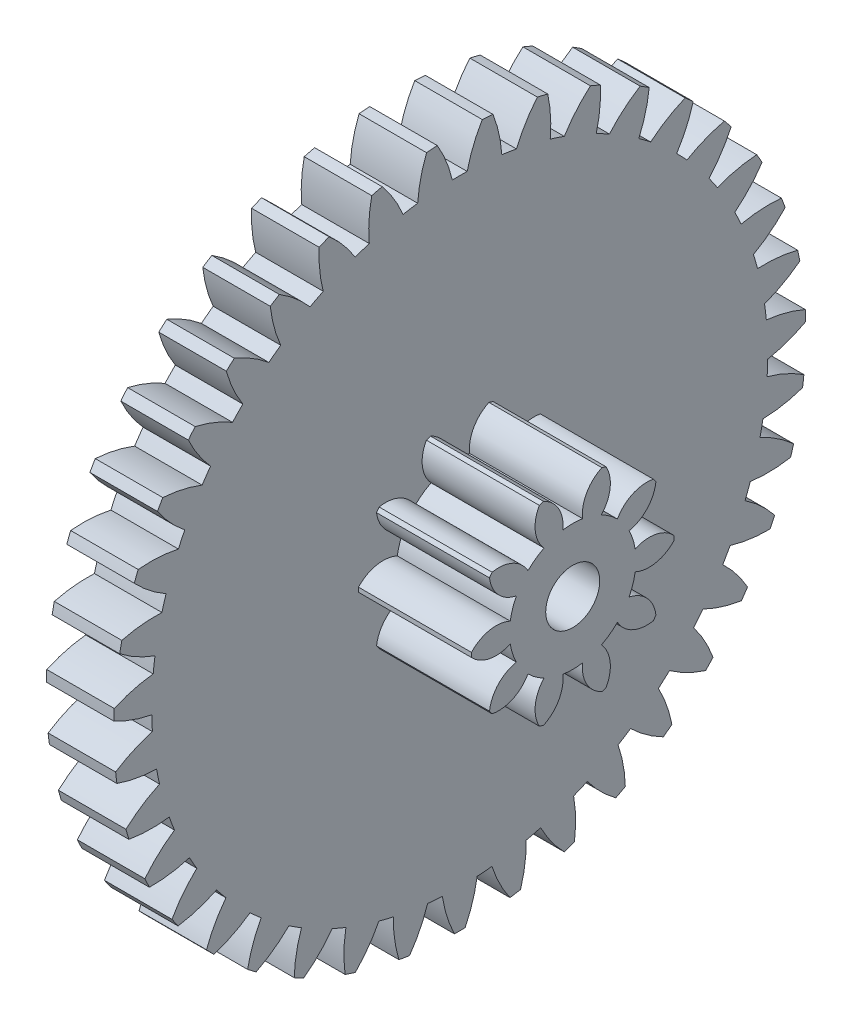
from build123d import *

# Parameters (mm, degrees)
ESQUISSE1_W                         = 1
ESQUISSE1_H                         = 5.125
ENL_V_MAT_EXTRU_1_DEPTH             = 2
ENL_V_MAT_EXTRU_2_DEPTH             = 2
ENL_V_MAT_EXTRU_3_DEPTH             = 2
ENL_V_MAT_EXTRU_4_DEPTH             = 2
ENL_V_MAT_EXTRU_5_DEPTH             = 2
ENL_V_MAT_EXTRU_6_DEPTH             = 2
ENL_V_MAT_EXTRU_7_DEPTH             = 2
ENL_V_MAT_EXTRU_8_DEPTH             = 2
ENL_V_MAT_EXTRU_9_DEPTH             = 2
ENL_V_MAT_EXTRU_10_DEPTH            = 2
ENL_V_MAT_EXTRU_11_DEPTH            = 2
ENL_V_MAT_EXTRU_12_DEPTH            = 2
ENL_V_MAT_EXTRU_13_DEPTH            = 2
ENL_V_MAT_EXTRU_14_DEPTH            = 2
ENL_V_MAT_EXTRU_15_DEPTH            = 2
ENL_V_MAT_EXTRU_16_DEPTH            = 2
ENL_V_MAT_EXTRU_17_DEPTH            = 2
ENL_V_MAT_EXTRU_18_DEPTH            = 2
ENL_V_MAT_EXTRU_19_DEPTH            = 2
ENL_V_MAT_EXTRU_20_DEPTH            = 2
ENL_V_MAT_EXTRU_21_DEPTH            = 2
ENL_V_MAT_EXTRU_22_DEPTH            = 2
ENL_V_MAT_EXTRU_23_DEPTH            = 2
ENL_V_MAT_EXTRU_24_DEPTH            = 2
ENL_V_MAT_EXTRU_25_DEPTH            = 2
ENL_V_MAT_EXTRU_26_DEPTH            = 2
ENL_V_MAT_EXTRU_27_DEPTH            = 2
ENL_V_MAT_EXTRU_28_DEPTH            = 2
ENL_V_MAT_EXTRU_29_DEPTH            = 2
ENL_V_MAT_EXTRU_30_DEPTH            = 2
ENL_V_MAT_EXTRU_31_DEPTH            = 2
ENL_V_MAT_EXTRU_32_DEPTH            = 2
ENL_V_MAT_EXTRU_33_DEPTH            = 2
ENL_V_MAT_EXTRU_34_DEPTH            = 2
ENL_V_MAT_EXTRU_35_DEPTH            = 2
ENL_V_MAT_EXTRU_36_DEPTH            = 2
ENL_V_MAT_EXTRU_37_DEPTH            = 2
ENL_V_MAT_EXTRU_38_DEPTH            = 2
ENL_V_MAT_EXTRU_39_DEPTH            = 2
BOSS_EXTRU_1_DEPTH                  = 1.672761457
DIAM_TRE_DU_PER_AGE_0_8_0_8_1_D     = 0.8
DIAM_TRE_DU_PER_AGE_0_8_0_8_1_DEPTH = 2.672761457


with BuildPart() as part:
    # Esquisse1 → Révolution1 (revolve)
    with BuildSketch(Plane(origin=(0, 0, 0), x_dir=(-1, 0, 0), z_dir=(0, 0, -1))):
        with Locations((-0.5, 2.5625)):
            Rectangle(ESQUISSE1_W, ESQUISSE1_H)
    revolve(axis=Axis((1, 0, 0), (-1, 0, 0)))

    # Esquisse2 → Enlèv. mat.-Extru.1 (cut, through all)
    with BuildSketch(Plane.ZY):
        with BuildLine():
            ThreePointArc((-0.491599352, 5.101367961), (-0.822107814, 5.058632596), (-1.149140058, 4.994507196))
            ThreePointArc((-1.149140058, 4.994507196), (-0.974871828, 4.75090918), (-0.839964848, 4.483496549))
            ThreePointArc((-0.839964848, 4.483496549), (-0.731716058, 4.502429773), (-0.623042589, 4.518749847))
            ThreePointArc((-0.623042589, 4.518749847), (-0.579759423, 4.815121196), (-0.491599352, 5.101367961))
        make_face()
    extrude(amount=-ENL_V_MAT_EXTRU_1_DEPTH, mode=Mode.SUBTRACT)

    # Esquisse3 → Enlèv. mat.-Extru.2 (cut, through all)
    with BuildSketch(Plane.ZY):
        with BuildLine():
            ThreePointArc((0.3330837, 5.114164668), (0, 5.125), (-0.3330837, 5.114164668))
            ThreePointArc((-0.3330837, 5.114164668), (-0.200148067, 4.845766593), (-0.1098841, 4.560176283))
            ThreePointArc((-0.1098841, 4.560176283), (0, 4.5615), (0.1098841, 4.560176283))
            ThreePointArc((0.1098841, 4.560176283), (0.200148067, 4.845766593), (0.3330837, 5.114164668))
        make_face()
    extrude(amount=-ENL_V_MAT_EXTRU_2_DEPTH, mode=Mode.SUBTRACT)

    # Esquisse4 → Enlèv. mat.-Extru.3 (cut, through all)
    with BuildSketch(Plane.ZY):
        with BuildLine():
            ThreePointArc((1.149140058, 4.994507196), (0.822107814, 5.058632596), (0.491599352, 5.101367961))
            ThreePointArc((0.491599352, 5.101367961), (0.579759423, 4.815121196), (0.623042589, 4.518749847))
            ThreePointArc((0.623042589, 4.518749847), (0.731716058, 4.502429773), (0.839964848, 4.483496549))
            ThreePointArc((0.839964848, 4.483496549), (0.974871828, 4.75090918), (1.149140058, 4.994507196))
        make_face()
    extrude(amount=-ENL_V_MAT_EXTRU_3_DEPTH, mode=Mode.SUBTRACT)

    # Esquisse5 → Enlèv. mat.-Extru.4 (cut, through all)
    with BuildSketch(Plane.ZY):
        with BuildLine():
            ThreePointArc((1.935434293, 4.745494611), (1.622923468, 4.861249265), (1.303550238, 4.956448504))
            ThreePointArc((1.303550238, 4.956448504), (1.34465145, 4.65976669), (1.339832802, 4.360290164))
            ThreePointArc((1.339832802, 4.360290164), (1.444481054, 4.32674898), (1.548290948, 4.290696609))
            ThreePointArc((1.548290948, 4.290696609), (1.724346921, 4.533005716), (1.935434293, 4.745494611))
        make_face()
    extrude(amount=-ENL_V_MAT_EXTRU_4_DEPTH, mode=Mode.SUBTRACT)

    # Esquisse6 → Enlèv. mat.-Extru.5 (cut, through all)
    with BuildSketch(Plane.ZY):
        with BuildLine():
            ThreePointArc((2.671601796, 4.373576208), (2.381706257, 4.537962131), (2.081739858, 4.683159635))
            ThreePointArc((2.081739858, 4.683159635), (2.07471771, 4.383726673), (2.021922049, 4.088901256))
            ThreePointArc((2.021922049, 4.088901256), (2.119834749, 4.039007661), (2.216517126, 3.986769881))
            ThreePointArc((2.216517126, 3.986769881), (2.429162334, 4.197699784), (2.671601796, 4.373576208))
        make_face()
    extrude(amount=-ENL_V_MAT_EXTRU_5_DEPTH, mode=Mode.SUBTRACT)

    # Esquisse7 → Enlèv. mat.-Extru.6 (cut, through all)
    with BuildSketch(Plane.ZY):
        with BuildLine():
            ThreePointArc((3.338576216, 3.888384478), (3.078804104, 4.097144162), (2.806013509, 4.28857939))
            ThreePointArc((2.806013509, 4.28857939), (2.751049871, 3.994150439), (2.651644577, 3.711611952))
            ThreePointArc((2.651644577, 3.711611952), (2.740285838, 3.646658165), (2.827336674, 3.579587907))
            ThreePointArc((2.827336674, 3.579587907), (3.071063719, 3.753675633), (3.338576216, 3.888384478))
        make_face()
    extrude(amount=-ENL_V_MAT_EXTRU_6_DEPTH, mode=Mode.SUBTRACT)

    # Esquisse8 → Enlèv. mat.-Extru.7 (cut, through all)
    with BuildSketch(Plane.ZY):
        with BuildLine():
            ThreePointArc((3.919083265, 3.302485634), (3.696162543, 3.550212312), (3.457612884, 3.782927193))
            ThreePointArc((3.457612884, 3.782927193), (3.356131286, 3.501127806), (3.212690904, 3.23819385))
            ThreePointArc((3.212690904, 3.23819385), (3.289764964, 3.159862139), (3.364929688, 3.079696486))
            ThreePointArc((3.364929688, 3.079696486), (3.633426167, 3.212433254), (3.919083265, 3.302485634))
        make_face()
    extrude(amount=-ENL_V_MAT_EXTRU_7_DEPTH, mode=Mode.SUBTRACT)

    # Esquisse9 → Enlèv. mat.-Extru.8 (cut, through all)
    with BuildSketch(Plane.ZY):
        with BuildLine():
            ThreePointArc((4.398088117, 2.631054146), (4.217792313, 2.911331827), (4.019661902, 3.179299168))
            ThreePointArc((4.019661902, 3.179299168), (3.874290663, 2.917427803), (3.690530223, 2.680908227))
            ThreePointArc((3.690530223, 2.680908227), (3.754040904, 2.591227342), (3.81537279, 2.500042544))
            ThreePointArc((3.81537279, 2.500042544), (4.101684785, 2.587990542), (4.398088117, 2.631054146))
        make_face()
    extrude(amount=-ENL_V_MAT_EXTRU_8_DEPTH, mode=Mode.SUBTRACT)

    # Esquisse10 → Enlèv. mat.-Extru.9 (cut, through all)
    with BuildSketch(Plane.ZY):
        with BuildLine():
            ThreePointArc((4.763184796, 1.891479738), (4.630183477, 2.197049377), (4.477603787, 2.493328964))
            ThreePointArc((4.477603787, 2.493328964), (4.292107947, 2.258167951), (4.072786749, 2.054188489))
            ThreePointArc((4.072786749, 2.054188489), (4.121089157, 1.955481119), (4.166999741, 1.855638814))
            ThreePointArc((4.166999741, 1.855638814), (4.463711922, 1.896520234), (4.763184796, 1.891479738))
        make_face()
    extrude(amount=-ENL_V_MAT_EXTRU_9_DEPTH, mode=Mode.SUBTRACT)

    # Esquisse11 → Enlèv. mat.-Extru.10 (cut, through all)
    with BuildSketch(Plane.ZY):
        with BuildLine():
            ThreePointArc((5.004917491, 1.102916998), (4.922655322, 1.425864503), (4.819578087, 1.74278285))
            ThreePointArc((4.819578087, 1.74278285), (4.59876189, 1.540422736), (4.349560237, 1.374266349))
            ThreePointArc((4.349560237, 1.374266349), (4.381403366, 1.269088962), (4.410703588, 1.163175012))
            ThreePointArc((4.410703588, 1.163175012), (4.710131265, 1.155931048), (5.004917491, 1.102916998))
        make_face()
    extrude(amount=-ENL_V_MAT_EXTRU_10_DEPTH, mode=Mode.SUBTRACT)

    # Esquisse12 → Enlèv. mat.-Extru.11 (cut, through all)
    with BuildSketch(Plane.ZY):
        with BuildLine():
            ThreePointArc((5.117025453, 0.285789287), (5.08763298, 0.617750486), (5.036727846, 0.947099576))
            ThreePointArc((5.036727846, 0.947099576), (4.786310315, 0.782781381), (4.513682399, 0.658751432))
            ThreePointArc((4.513682399, 0.658751432), (4.528241529, 0.549828067), (4.540172528, 0.440585589))
            ThreePointArc((4.540172528, 0.440585589), (4.834560682, 0.385403856), (5.117025453, 0.285789287))
        make_face()
    extrude(amount=-ENL_V_MAT_EXTRU_11_DEPTH, mode=Mode.SUBTRACT)

    # Esquisse13 → Enlèv. mat.-Extru.12 (cut, through all)
    with BuildSketch(Plane.ZY):
        with BuildLine():
            ThreePointArc((5.096605143, -0.538740217), (5.120843616, -0.206362943), (5.123428999, 0.12688692))
            ThreePointArc((5.123428999, 0.12688692), (4.849895818, 0.0048664), (4.560902559, -0.073824801))
            ThreePointArc((4.560902559, -0.073824801), (4.557800615, -0.183673086), (4.552053385, -0.293414769))
            ThreePointArc((4.552053385, -0.293414769), (4.833777517, -0.395105094), (5.096605143, -0.538740217))
        make_face()
    extrude(amount=-ENL_V_MAT_EXTRU_12_DEPTH, mode=Mode.SUBTRACT)

    # Esquisse14 → Enlèv. mat.-Extru.13 (cut, through all)
    with BuildSketch(Plane.ZY):
        with BuildLine():
            ThreePointArc((4.944185436, -1.349316631), (5.021427092, -1.025131681), (5.077436033, -0.69661204))
            ThreePointArc((5.077436033, -0.69661204), (4.787871566, -0.773174619), (4.489997737, -0.804489011))
            ThreePointArc((4.489997737, -0.804489011), (4.469315059, -0.912417202), (4.446038451, -1.019815839))
            ThreePointArc((4.446038451, -1.019815839), (4.707802054, -1.16538103), (4.944185436, -1.349316631))
        make_face()
    extrude(amount=-ENL_V_MAT_EXTRU_13_DEPTH, mode=Mode.SUBTRACT)

    # Esquisse15 → Enlèv. mat.-Extru.14 (cut, through all)
    with BuildSketch(Plane.ZY):
        with BuildLine():
            ThreePointArc((4.663713924, -2.124946454), (4.791958244, -1.817350046), (4.89994014, -1.502069115))
            ThreePointArc((4.89994014, -1.502069115), (4.601843956, -1.531190821), (4.302804333, -1.514317378))
            ThreePointArc((4.302804333, -1.514317378), (4.265076591, -1.617530192), (4.224873456, -1.719804214))
            ThreePointArc((4.224873456, -1.719804214), (4.45989699, -1.905474209), (4.663713924, -2.124946454))
        make_face()
    extrude(amount=-ENL_V_MAT_EXTRU_14_DEPTH, mode=Mode.SUBTRACT)

    # Esquisse16 → Enlèv. mat.-Extru.15 (cut, through all)
    with BuildSketch(Plane.ZY):
        with BuildLine():
            ThreePointArc((4.262454672, -2.845541279), (4.438380194, -2.5625), (4.595538371, -2.268623388))
            ThreePointArc((4.595538371, -2.268623388), (4.296631004, -2.249549986), (4.004170557, -2.18492572))
            ThreePointArc((4.004170557, -2.18492572), (3.950374879, -2.28075), (3.894286457, -2.375250564))
            ThreePointArc((3.894286457, -2.375250564), (4.096482937, -2.596216607), (4.262454672, -2.845541279))
        make_face()
    extrude(amount=-ENL_V_MAT_EXTRU_15_DEPTH, mode=Mode.SUBTRACT)

    # Esquisse17 → Enlèv. mat.-Extru.16 (cut, through all)
    with BuildSketch(Plane.ZY):
        with BuildLine():
            ThreePointArc((3.750800082, -3.492438081), (3.969850429, -3.24128255), (4.172114573, -2.976421508))
            ThreePointArc((4.172114573, -2.976421508), (3.880137567, -2.909646987), (3.601830867, -2.798945633))
            ThreePointArc((3.601830867, -2.798945633), (3.533360533, -2.884899581), (3.462839485, -2.969179171))
            ThreePointArc((3.462839485, -2.969179171), (3.626972127, -3.219718359), (3.750800082, -3.492438081))
        make_face()
    extrude(amount=-ENL_V_MAT_EXTRU_16_DEPTH, mode=Mode.SUBTRACT)

    # Esquisse18 → Enlèv. mat.-Extru.17 (cut, through all)
    with BuildSketch(Plane.ZY):
        with BuildLine():
            ThreePointArc((3.14200174, -4.04888257), (3.398503623, -3.836117584), (3.640635198, -3.607131873))
            ThreePointArc((3.640635198, -3.607131873), (3.363150604, -3.49438566), (3.106205649, -3.340474325))
            ThreePointArc((3.106205649, -3.340474325), (3.024834006, -3.414331778), (2.941706789, -3.486207598))
            ThreePointArc((2.941706789, -3.486207598), (3.063524645, -3.759831097), (3.14200174, -4.04888257))
        make_face()
    extrude(amount=-ENL_V_MAT_EXTRU_17_DEPTH, mode=Mode.SUBTRACT)

    # Esquisse19 → Enlèv. mat.-Extru.18 (cut, through all)
    with BuildSketch(Plane.ZY):
        with BuildLine():
            ThreePointArc((2.451827203, -4.500463128), (2.739137359, -4.331599188), (3.014865285, -4.144419418))
            ThreePointArc((3.014865285, -4.144419418), (2.759059808, -3.988621579), (2.530131336, -3.795486487))
            ThreePointArc((2.530131336, -3.795486487), (2.437965866, -3.855334575), (2.344385433, -3.912945079))
            ThreePointArc((2.344385433, -3.912945079), (2.420733483, -4.202566184), (2.451827203, -4.500463128))
        make_face()
    extrude(amount=-ENL_V_MAT_EXTRU_18_DEPTH, mode=Mode.SUBTRACT)

    # Esquisse20 → Enlèv. mat.-Extru.19 (cut, through all)
    with BuildSketch(Plane.ZY):
        with BuildLine():
            ThreePointArc((1.69815163, -4.835484054), (2.008828876, -4.714894649), (2.311011944, -4.574368677))
            ThreePointArc((2.311011944, -4.574368677), (2.083510811, -4.379554295), (1.888527951, -4.152197542))
            ThreePointArc((1.888527951, -4.152197542), (1.787955691, -4.196486232), (1.686345725, -4.238339338))
            ThreePointArc((1.686345725, -4.238339338), (1.715246596, -4.536457014), (1.69815163, -4.835484054))
        make_face()
    extrude(amount=-ENL_V_MAT_EXTRU_19_DEPTH, mode=Mode.SUBTRACT)

    # Esquisse21 → Enlèv. mat.-Extru.20 (cut, through all)
    with BuildSketch(Plane.ZY):
        with BuildLine():
            ThreePointArc((0.900494822, -5.045268484), (1.226492779, -4.976076814), (1.547304608, -4.88584419))
            ThreePointArc((1.547304608, -4.88584419), (1.35399998, -4.657058855), (1.198012684, -4.401368862))
            ThreePointArc((1.198012684, -4.401368862), (1.091638403, -4.4289511), (0.984630549, -4.453962835))
            ThreePointArc((0.984630549, -4.453962835), (0.965335723, -4.75285599), (0.900494822, -5.045268484))
        make_face()
    extrude(amount=-ENL_V_MAT_EXTRU_20_DEPTH, mode=Mode.SUBTRACT)

    # Esquisse22 → Enlèv. mat.-Extru.21 (cut, through all)
    with BuildSketch(Plane.ZY):
        with BuildLine():
            ThreePointArc((0.079515671, -5.12438311), (0.412391165, -5.108381204), (0.743522895, -5.070778905))
            ThreePointArc((0.743522895, -5.070778905), (0.589421259, -4.813948037), (0.476469518, -4.53654704))
            ThreePointArc((0.476469518, -4.53654704), (0.367048253, -4.546708461), (0.257413959, -4.554231033))
            ThreePointArc((0.257413959, -4.554231033), (0.190423162, -4.846158493), (0.079515671, -5.12438311))
        make_face()
    extrude(amount=-ENL_V_MAT_EXTRU_21_DEPTH, mode=Mode.SUBTRACT)

    # Esquisse23 → Enlèv. mat.-Extru.22 (cut, through all)
    with BuildSketch(Plane.ZY):
        with BuildLine():
            ThreePointArc((-0.743522895, -5.070778905), (-0.412391165, -5.108381204), (-0.079515671, -5.12438311))
            ThreePointArc((-0.079515671, -5.12438311), (-0.190423162, -4.846158493), (-0.257413959, -4.554231033))
            ThreePointArc((-0.257413959, -4.554231033), (-0.367048253, -4.546708461), (-0.476469518, -4.53654704))
            ThreePointArc((-0.476469518, -4.53654704), (-0.589421259, -4.813948037), (-0.743522895, -5.070778905))
        make_face()
    extrude(amount=-ENL_V_MAT_EXTRU_22_DEPTH, mode=Mode.SUBTRACT)

    # Esquisse24 → Enlèv. mat.-Extru.23 (cut, through all)
    with BuildSketch(Plane.ZY):
        with BuildLine():
            ThreePointArc((-1.547304608, -4.88584419), (-1.226492779, -4.976076814), (-0.900494822, -5.045268484))
            ThreePointArc((-0.900494822, -5.045268484), (-0.965335723, -4.75285599), (-0.984630549, -4.453962835))
            ThreePointArc((-0.984630549, -4.453962835), (-1.091638403, -4.4289511), (-1.198012684, -4.401368862))
            ThreePointArc((-1.198012684, -4.401368862), (-1.35399998, -4.657058855), (-1.547304608, -4.88584419))
        make_face()
    extrude(amount=-ENL_V_MAT_EXTRU_23_DEPTH, mode=Mode.SUBTRACT)

    # Esquisse25 → Enlèv. mat.-Extru.24 (cut, through all)
    with BuildSketch(Plane.ZY):
        with BuildLine():
            ThreePointArc((-2.311011944, -4.574368677), (-2.008828876, -4.714894649), (-1.69815163, -4.835484054))
            ThreePointArc((-1.69815163, -4.835484054), (-1.715246596, -4.536457014), (-1.686345725, -4.238339338))
            ThreePointArc((-1.686345725, -4.238339338), (-1.787955691, -4.196486232), (-1.888527951, -4.152197542))
            ThreePointArc((-1.888527951, -4.152197542), (-2.083510811, -4.379554295), (-2.311011944, -4.574368677))
        make_face()
    extrude(amount=-ENL_V_MAT_EXTRU_24_DEPTH, mode=Mode.SUBTRACT)

    # Esquisse26 → Enlèv. mat.-Extru.25 (cut, through all)
    with BuildSketch(Plane.ZY):
        with BuildLine():
            ThreePointArc((-3.014865285, -4.144419418), (-2.739137359, -4.331599188), (-2.451827203, -4.500463128))
            ThreePointArc((-2.451827203, -4.500463128), (-2.420733483, -4.202566184), (-2.344385433, -3.912945079))
            ThreePointArc((-2.344385433, -3.912945079), (-2.437965866, -3.855334575), (-2.530131336, -3.795486487))
            ThreePointArc((-2.530131336, -3.795486487), (-2.759059808, -3.988621579), (-3.014865285, -4.144419418))
        make_face()
    extrude(amount=-ENL_V_MAT_EXTRU_25_DEPTH, mode=Mode.SUBTRACT)

    # Esquisse27 → Enlèv. mat.-Extru.26 (cut, through all)
    with BuildSketch(Plane.ZY):
        with BuildLine():
            ThreePointArc((-3.640635198, -3.607131873), (-3.398503623, -3.836117584), (-3.14200174, -4.04888257))
            ThreePointArc((-3.14200174, -4.04888257), (-3.063524645, -3.759831097), (-2.941706789, -3.486207598))
            ThreePointArc((-2.941706789, -3.486207598), (-3.024834006, -3.414331778), (-3.106205649, -3.340474325))
            ThreePointArc((-3.106205649, -3.340474325), (-3.363150604, -3.49438566), (-3.640635198, -3.607131873))
        make_face()
    extrude(amount=-ENL_V_MAT_EXTRU_26_DEPTH, mode=Mode.SUBTRACT)

    # Esquisse28 → Enlèv. mat.-Extru.27 (cut, through all)
    with BuildSketch(Plane.ZY):
        with BuildLine():
            ThreePointArc((-4.172114573, -2.976421508), (-3.969850429, -3.24128255), (-3.750800082, -3.492438081))
            ThreePointArc((-3.750800082, -3.492438081), (-3.626972127, -3.219718359), (-3.462839485, -2.969179171))
            ThreePointArc((-3.462839485, -2.969179171), (-3.533360533, -2.884899581), (-3.601830867, -2.798945633))
            ThreePointArc((-3.601830867, -2.798945633), (-3.880137567, -2.909646987), (-4.172114573, -2.976421508))
        make_face()
    extrude(amount=-ENL_V_MAT_EXTRU_27_DEPTH, mode=Mode.SUBTRACT)

    # Esquisse29 → Enlèv. mat.-Extru.28 (cut, through all)
    with BuildSketch(Plane.ZY):
        with BuildLine():
            ThreePointArc((-4.595538371, -2.268623388), (-4.438380194, -2.5625), (-4.262454672, -2.845541279))
            ThreePointArc((-4.262454672, -2.845541279), (-4.096482937, -2.596216607), (-3.894286457, -2.375250564))
            ThreePointArc((-3.894286457, -2.375250564), (-3.950374879, -2.28075), (-4.004170557, -2.18492572))
            ThreePointArc((-4.004170557, -2.18492572), (-4.296631004, -2.249549986), (-4.595538371, -2.268623388))
        make_face()
    extrude(amount=-ENL_V_MAT_EXTRU_28_DEPTH, mode=Mode.SUBTRACT)

    # Esquisse30 → Enlèv. mat.-Extru.29 (cut, through all)
    with BuildSketch(Plane.ZY):
        with BuildLine():
            ThreePointArc((-4.89994014, -1.502069115), (-4.791958244, -1.817350046), (-4.663713924, -2.124946454))
            ThreePointArc((-4.663713924, -2.124946454), (-4.45989699, -1.905474209), (-4.224873456, -1.719804214))
            ThreePointArc((-4.224873456, -1.719804214), (-4.265076591, -1.617530192), (-4.302804333, -1.514317378))
            ThreePointArc((-4.302804333, -1.514317378), (-4.601843956, -1.531190821), (-4.89994014, -1.502069115))
        make_face()
    extrude(amount=-ENL_V_MAT_EXTRU_29_DEPTH, mode=Mode.SUBTRACT)

    # Esquisse31 → Enlèv. mat.-Extru.30 (cut, through all)
    with BuildSketch(Plane.ZY):
        with BuildLine():
            ThreePointArc((-5.077436033, -0.69661204), (-5.021427092, -1.025131681), (-4.944185436, -1.349316631))
            ThreePointArc((-4.944185436, -1.349316631), (-4.707802054, -1.16538103), (-4.446038451, -1.019815839))
            ThreePointArc((-4.446038451, -1.019815839), (-4.469315059, -0.912417202), (-4.489997737, -0.804489011))
            ThreePointArc((-4.489997737, -0.804489011), (-4.787871566, -0.773174619), (-5.077436033, -0.69661204))
        make_face()
    extrude(amount=-ENL_V_MAT_EXTRU_30_DEPTH, mode=Mode.SUBTRACT)

    # Esquisse32 → Enlèv. mat.-Extru.31 (cut, through all)
    with BuildSketch(Plane.ZY):
        with BuildLine():
            ThreePointArc((-5.123428999, 0.12688692), (-5.120843616, -0.206362943), (-5.096605143, -0.538740217))
            ThreePointArc((-5.096605143, -0.538740217), (-4.833777517, -0.395105094), (-4.552053385, -0.293414769))
            ThreePointArc((-4.552053385, -0.293414769), (-4.557800615, -0.183673086), (-4.560902559, -0.073824801))
            ThreePointArc((-4.560902559, -0.073824801), (-4.849895818, 0.0048664), (-5.123428999, 0.12688692))
        make_face()
    extrude(amount=-ENL_V_MAT_EXTRU_31_DEPTH, mode=Mode.SUBTRACT)

    # Esquisse33 → Enlèv. mat.-Extru.32 (cut, through all)
    with BuildSketch(Plane.ZY):
        with BuildLine():
            ThreePointArc((-5.036727846, 0.947099576), (-5.08763298, 0.617750486), (-5.117025453, 0.285789287))
            ThreePointArc((-5.117025453, 0.285789287), (-4.834560682, 0.385403856), (-4.540172528, 0.440585589))
            ThreePointArc((-4.540172528, 0.440585589), (-4.528241529, 0.549828067), (-4.513682399, 0.658751432))
            ThreePointArc((-4.513682399, 0.658751432), (-4.786310315, 0.782781381), (-5.036727846, 0.947099576))
        make_face()
    extrude(amount=-ENL_V_MAT_EXTRU_32_DEPTH, mode=Mode.SUBTRACT)

    # Esquisse34 → Enlèv. mat.-Extru.33 (cut, through all)
    with BuildSketch(Plane.ZY):
        with BuildLine():
            ThreePointArc((-4.819578087, 1.74278285), (-4.922655322, 1.425864503), (-5.004917491, 1.102916998))
            ThreePointArc((-5.004917491, 1.102916998), (-4.710131265, 1.155931048), (-4.410703588, 1.163175012))
            ThreePointArc((-4.410703588, 1.163175012), (-4.381403366, 1.269088962), (-4.349560237, 1.374266349))
            ThreePointArc((-4.349560237, 1.374266349), (-4.59876189, 1.540422736), (-4.819578087, 1.74278285))
        make_face()
    extrude(amount=-ENL_V_MAT_EXTRU_33_DEPTH, mode=Mode.SUBTRACT)

    # Esquisse35 → Enlèv. mat.-Extru.34 (cut, through all)
    with BuildSketch(Plane.ZY):
        with BuildLine():
            ThreePointArc((-4.477603787, 2.493328964), (-4.630183477, 2.197049377), (-4.763184796, 1.891479738))
            ThreePointArc((-4.763184796, 1.891479738), (-4.463711922, 1.896520234), (-4.166999741, 1.855638814))
            ThreePointArc((-4.166999741, 1.855638814), (-4.121089157, 1.955481119), (-4.072786749, 2.054188489))
            ThreePointArc((-4.072786749, 2.054188489), (-4.292107947, 2.258167951), (-4.477603787, 2.493328964))
        make_face()
    extrude(amount=-ENL_V_MAT_EXTRU_34_DEPTH, mode=Mode.SUBTRACT)

    # Esquisse36 → Enlèv. mat.-Extru.35 (cut, through all)
    with BuildSketch(Plane.ZY):
        with BuildLine():
            ThreePointArc((-4.019661902, 3.179299168), (-4.217792313, 2.911331827), (-4.398088117, 2.631054146))
            ThreePointArc((-4.398088117, 2.631054146), (-4.101684785, 2.587990542), (-3.81537279, 2.500042544))
            ThreePointArc((-3.81537279, 2.500042544), (-3.754040904, 2.591227342), (-3.690530223, 2.680908227))
            ThreePointArc((-3.690530223, 2.680908227), (-3.874290663, 2.917427803), (-4.019661902, 3.179299168))
        make_face()
    extrude(amount=-ENL_V_MAT_EXTRU_35_DEPTH, mode=Mode.SUBTRACT)

    # Esquisse37 → Enlèv. mat.-Extru.36 (cut, through all)
    with BuildSketch(Plane.ZY):
        with BuildLine():
            ThreePointArc((-3.457612884, 3.782927193), (-3.696162543, 3.550212312), (-3.919083265, 3.302485634))
            ThreePointArc((-3.919083265, 3.302485634), (-3.633426167, 3.212433254), (-3.364929688, 3.079696486))
            ThreePointArc((-3.364929688, 3.079696486), (-3.289764964, 3.159862139), (-3.212690904, 3.23819385))
            ThreePointArc((-3.212690904, 3.23819385), (-3.356131286, 3.501127806), (-3.457612884, 3.782927193))
        make_face()
    extrude(amount=-ENL_V_MAT_EXTRU_36_DEPTH, mode=Mode.SUBTRACT)

    # Esquisse38 → Enlèv. mat.-Extru.37 (cut, through all)
    with BuildSketch(Plane.ZY):
        with BuildLine():
            ThreePointArc((-2.806013509, 4.28857939), (-3.078804104, 4.097144162), (-3.338576216, 3.888384478))
            ThreePointArc((-3.338576216, 3.888384478), (-3.071063719, 3.753675633), (-2.827336674, 3.579587907))
            ThreePointArc((-2.827336674, 3.579587907), (-2.740285838, 3.646658165), (-2.651644577, 3.711611952))
            ThreePointArc((-2.651644577, 3.711611952), (-2.751049871, 3.994150439), (-2.806013509, 4.28857939))
        make_face()
    extrude(amount=-ENL_V_MAT_EXTRU_37_DEPTH, mode=Mode.SUBTRACT)

    # Esquisse39 → Enlèv. mat.-Extru.38 (cut, through all)
    with BuildSketch(Plane.ZY):
        with BuildLine():
            ThreePointArc((-2.081739858, 4.683159635), (-2.381706257, 4.537962131), (-2.671601796, 4.373576208))
            ThreePointArc((-2.671601796, 4.373576208), (-2.429162334, 4.197699784), (-2.216517126, 3.986769881))
            ThreePointArc((-2.216517126, 3.986769881), (-2.119834749, 4.039007661), (-2.021922049, 4.088901256))
            ThreePointArc((-2.021922049, 4.088901256), (-2.07471771, 4.383726673), (-2.081739858, 4.683159635))
        make_face()
    extrude(amount=-ENL_V_MAT_EXTRU_38_DEPTH, mode=Mode.SUBTRACT)

    # Esquisse40 → Enlèv. mat.-Extru.39 (cut, through all)
    with BuildSketch(Plane.ZY):
        with BuildLine():
            ThreePointArc((-1.303550238, 4.956448504), (-1.622923468, 4.861249265), (-1.935434293, 4.745494611))
            ThreePointArc((-1.935434293, 4.745494611), (-1.724346921, 4.533005716), (-1.548290948, 4.290696609))
            ThreePointArc((-1.548290948, 4.290696609), (-1.444481054, 4.32674898), (-1.339832802, 4.360290164))
            ThreePointArc((-1.339832802, 4.360290164), (-1.34465145, 4.65976669), (-1.303550238, 4.956448504))
        make_face()
    extrude(amount=-ENL_V_MAT_EXTRU_39_DEPTH, mode=Mode.SUBTRACT)

    # Esquisse41 → Boss.-Extru.1 (add)
    with BuildSketch(Plane(origin=(1, 0, 0), x_dir=(0, 0, -1), z_dir=(1, 0, 0))):
        with BuildLine():
            ThreePointArc((0.662076845, 0.662334131), (0.888221597, 0.871258232), (1.193891961, 0.908086992))
            ThreePointArc((1.193891961, 0.908086992), (1.213525492, 0.881677878), (1.232574957, 0.854844416))
            ThreePointArc((1.232574957, 0.854844416), (1.103091387, 0.575515338), (0.834510188, 0.424999995))
            ThreePointArc((0.834510188, 0.424999995), (0.890664428, 0.289394415), (0.924941654, 0.146680563))
            ThreePointArc((0.924941654, 0.146680563), (1.230699107, 0.18277916), (1.499639028, 0.032905721))
            ThreePointArc((1.499639028, 0.032905721), (1.5, 0), (1.499639028, -0.032905721))
            ThreePointArc((1.499639028, -0.032905721), (1.230699107, -0.18277916), (0.924941654, -0.146680563))
            ThreePointArc((0.924941654, -0.146680563), (0.890664428, -0.289394415), (0.834510188, -0.424999995))
            ThreePointArc((0.834510188, -0.424999995), (1.103091387, -0.575515338), (1.232574957, -0.854844416))
            ThreePointArc((1.232574957, -0.854844416), (1.213525492, -0.881677878), (1.193891961, -0.908086992))
            ThreePointArc((1.193891961, -0.908086992), (0.888221597, -0.871258232), (0.662076845, -0.662334131))
            ThreePointArc((0.662076845, -0.662334131), (0.550460889, -0.757644415), (0.425324195, -0.834345))
            ThreePointArc((0.425324195, -0.834345), (0.55414025, -1.113982538), (0.494709146, -1.416073042))
            ThreePointArc((0.494709146, -1.416073042), (0.463525492, -1.426584774), (0.432118744, -1.436409897))
            ThreePointArc((0.432118744, -1.436409897), (0.206473627, -1.226946272), (0.146321185, -0.924998573))
            ThreePointArc((0.146321185, -0.924998573), (0, -0.9365), (-0.146321185, -0.924998573))
            ThreePointArc((-0.146321185, -0.924998573), (-0.206473627, -1.226946272), (-0.432118744, -1.436409897))
            ThreePointArc((-0.432118744, -1.436409897), (-0.463525492, -1.426584774), (-0.494709146, -1.416073042))
            ThreePointArc((-0.494709146, -1.416073042), (-0.55414025, -1.113982538), (-0.425324195, -0.834345))
            ThreePointArc((-0.425324195, -0.834345), (-0.550460889, -0.757644415), (-0.662076845, -0.662334131))
            ThreePointArc((-0.662076845, -0.662334131), (-0.888221597, -0.871258232), (-1.193891961, -0.908086992))
            ThreePointArc((-1.193891961, -0.908086992), (-1.213525492, -0.881677878), (-1.232574957, -0.854844416))
            ThreePointArc((-1.232574957, -0.854844416), (-1.103091387, -0.575515338), (-0.834510188, -0.424999995))
            ThreePointArc((-0.834510188, -0.424999995), (-0.890664428, -0.289394415), (-0.924941654, -0.146680563))
            ThreePointArc((-0.924941654, -0.146680563), (-1.230699107, -0.18277916), (-1.499639028, -0.032905721))
            ThreePointArc((-1.499639028, -0.032905721), (-1.5, 0), (-1.499639028, 0.032905721))
            ThreePointArc((-1.499639028, 0.032905721), (-1.230699107, 0.18277916), (-0.924941654, 0.146680563))
            ThreePointArc((-0.924941654, 0.146680563), (-0.890664428, 0.289394415), (-0.834510188, 0.424999995))
            ThreePointArc((-0.834510188, 0.424999995), (-1.103091387, 0.575515338), (-1.232574957, 0.854844416))
            ThreePointArc((-1.232574957, 0.854844416), (-1.213525492, 0.881677878), (-1.193891961, 0.908086992))
            ThreePointArc((-1.193891961, 0.908086992), (-0.888221597, 0.871258232), (-0.662076845, 0.662334131))
            ThreePointArc((-0.662076845, 0.662334131), (-0.550460889, 0.757644415), (-0.425324195, 0.834345))
            ThreePointArc((-0.425324195, 0.834345), (-0.55414025, 1.113982538), (-0.494709146, 1.416073042))
            ThreePointArc((-0.494709146, 1.416073042), (-0.463525492, 1.426584774), (-0.432118744, 1.436409897))
            ThreePointArc((-0.432118744, 1.436409897), (-0.206473627, 1.226946272), (-0.146321185, 0.924998573))
            ThreePointArc((-0.146321185, 0.924998573), (0, 0.9365), (0.146321185, 0.924998573))
            ThreePointArc((0.146321185, 0.924998573), (0.206473627, 1.226946272), (0.432118744, 1.436409897))
            ThreePointArc((0.432118744, 1.436409897), (0.463525492, 1.426584774), (0.494709146, 1.416073042))
            ThreePointArc((0.494709146, 1.416073042), (0.55414025, 1.113982538), (0.425324195, 0.834345))
            ThreePointArc((0.425324195, 0.834345), (0.550460889, 0.757644415), (0.662076845, 0.662334131))
        make_face()
    extrude(amount=BOSS_EXTRU_1_DEPTH)

    # Diamètre du perçage Ø0.8 (0.8)1
    with Locations(Plane.ZY):
        with Locations((0, 0)):
            Hole(DIAM_TRE_DU_PER_AGE_0_8_0_8_1_D / 2, depth=DIAM_TRE_DU_PER_AGE_0_8_0_8_1_DEPTH)


solid = part.part
